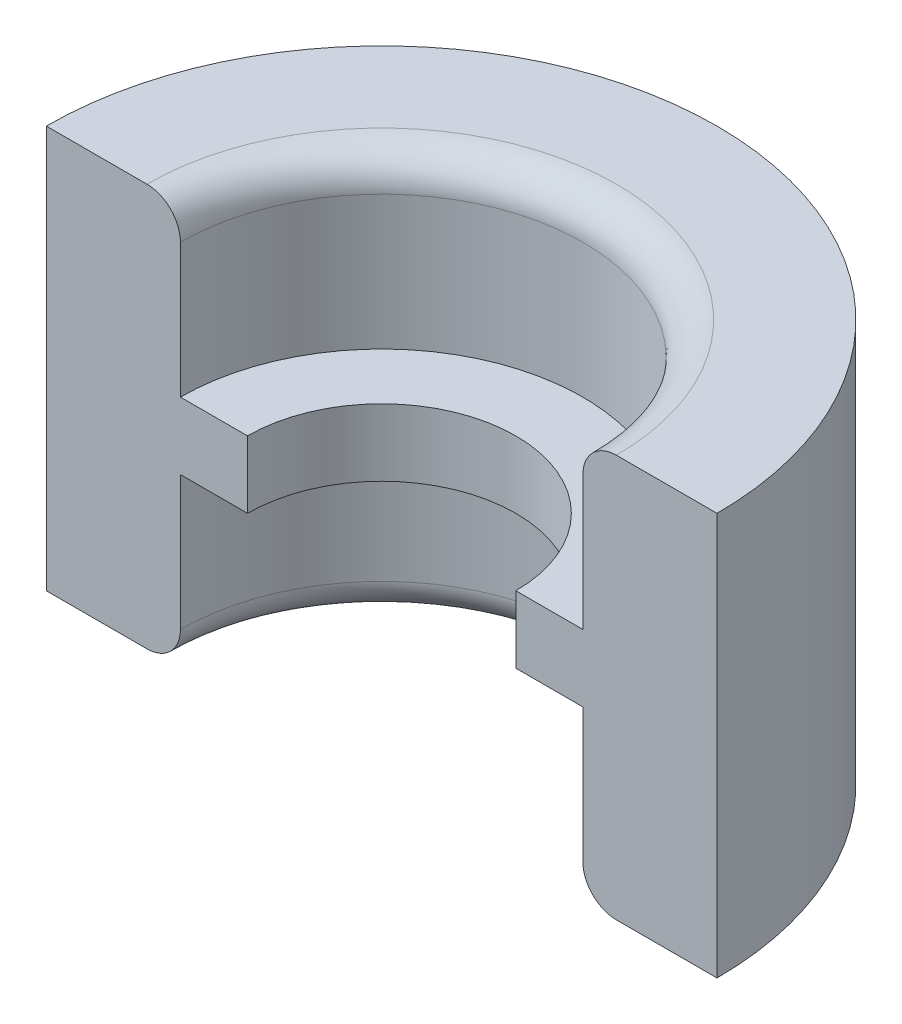
from build123d import *

# Parameters (mm, degrees)
SKETCH1_W      = 1
SKETCH1_H      = 1
SKETCH1_W_2    = 2
SKETCH1_H_2    = 6
REVOLVE2_ANGLE = 180
FILLET3_R      = 0.5


with BuildPart() as part:
    # Sketch1 → Revolve2 (revolve)
    with BuildSketch(Plane.XY):
        with Locations((2.5, 0)):
            Rectangle(SKETCH1_W, SKETCH1_H)
        with Locations((4, 0)):
            Rectangle(SKETCH1_W_2, SKETCH1_H_2)
    revolve(axis=Axis((0, 0, 0), (0, 1, 0)), revolution_arc=REVOLVE2_ANGLE)

    # Fillet3
    fillet3_edges = [part.edges().sort_by_distance(p)[0] for p in [
        (0, 3, -3),
        (0, -3, -3),
    ]]
    fillet(fillet3_edges, radius=FILLET3_R)


solid = part.part
